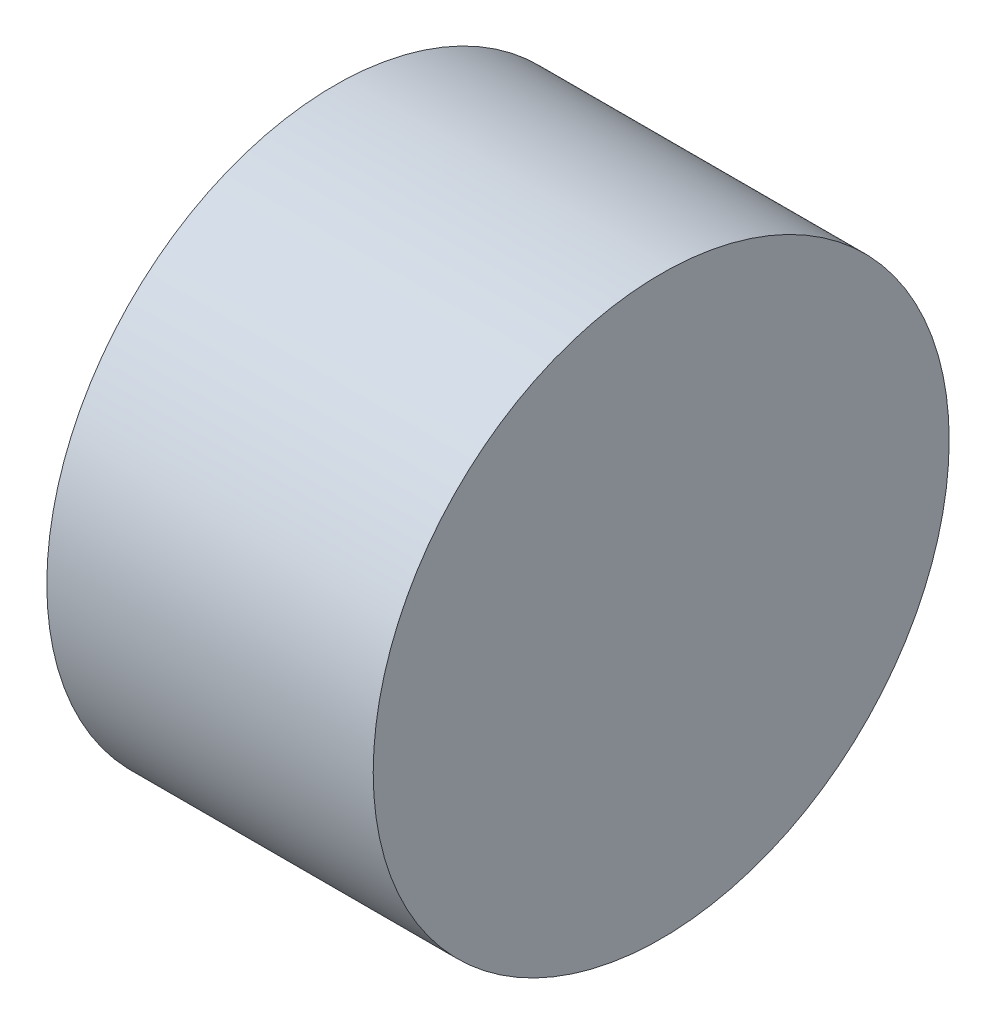
from build123d import *

# Parameters (mm, degrees)
SKETCH1_R           = 3
BOSS_EXTRUDE1_DEPTH = 3.4


with BuildPart() as part:
    # Sketch1 → Boss-Extrude1 (new body)
    with BuildSketch(Plane(origin=(0, 0, 0), x_dir=(0, 0, -1), z_dir=(1, 0, 0))):
        Circle(SKETCH1_R)
    extrude(amount=BOSS_EXTRUDE1_DEPTH)


solid = part.part
